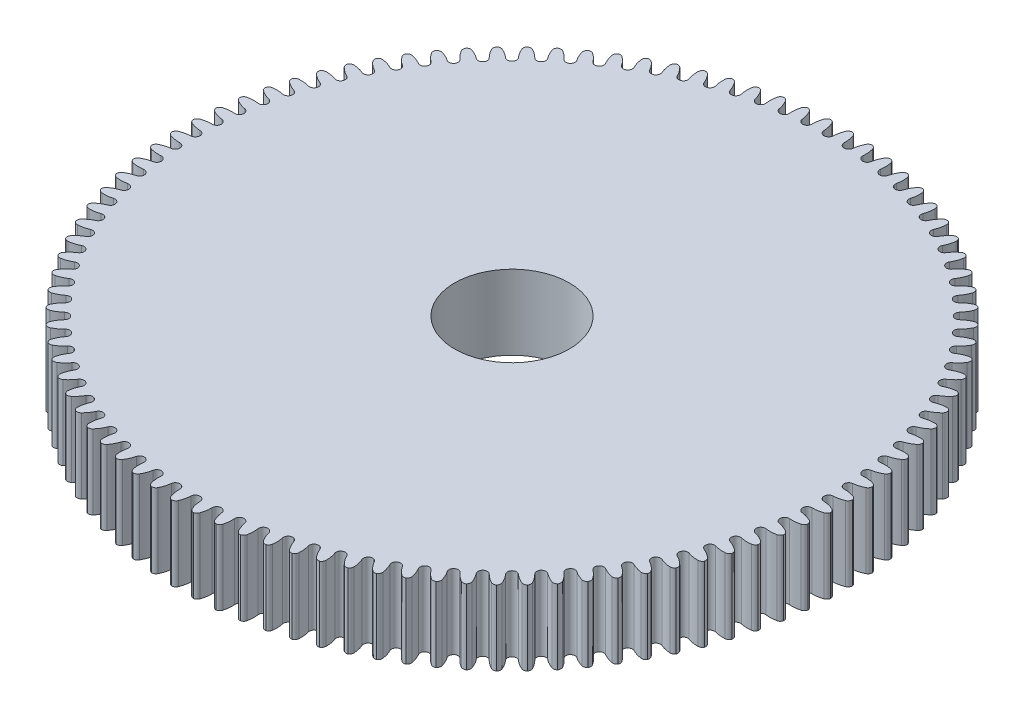
from build123d import *

# Parameters (mm, degrees)
SKETCH1_R           = 57.5
BOSS_EXTRUDE1_DEPTH = 13
CUT_EXTRUDE1_DEPTH  = 13
CIRPATTERN1_COUNT   = 96
SKETCH4_R           = 10
CUT_EXTRUDE3_DEPTH  = 13


with BuildPart() as part:
    # Sketch1 → Boss-Extrude1 (new body)
    with BuildSketch(Plane(origin=(0, 0, 0), x_dir=(1, 0, 0), z_dir=(0, 1, 0))):
        Circle(SKETCH1_R)
    extrude(amount=BOSS_EXTRUDE1_DEPTH)

    # Sketch3 → Cut-Extrude1 (cut)
    with BuildSketch(Plane.XZ):
        with BuildLine():
            ThreePointArc((1.210058579, -56.980264877), (0.924049006, -56.098471263), (0.799158179, -55.179905133))
            ThreePointArc((0.799158179, -55.179905133), (0, -54.416595794), (-0.799158179, -55.179905133))
            ThreePointArc((-0.799158179, -55.179905133), (-0.924049006, -56.098471263), (-1.210058579, -56.980264877))
            ThreePointArc((-1.210058579, -56.980264877), (-1.516463273, -57.341501027), (-1.973458227, -57.466124479))
            ThreePointArc((-1.973458227, -57.466124479), (3e-09, -57.5), (1.973458233, -57.466124479))
            ThreePointArc((1.973458233, -57.466124479), (1.516463276, -57.341501029), (1.210058579, -56.980264877))
        make_face()
    cut_extrude1 = extrude(amount=-CUT_EXTRUDE1_DEPTH, mode=Mode.SUBTRACT)

    # CirPattern1: Cut-Extrude1 ×96 about axis
    cirpattern1_axis = Axis((0, 0, 0), (0, 1, 0))
    for i in range(1, CIRPATTERN1_COUNT):
        add(cut_extrude1.rotate(cirpattern1_axis, i * 360 / CIRPATTERN1_COUNT), mode=Mode.SUBTRACT)

    # Sketch4 → Cut-Extrude3 (cut)
    with BuildSketch(Plane.XZ):
        Circle(SKETCH4_R)
    extrude(amount=-CUT_EXTRUDE3_DEPTH, mode=Mode.SUBTRACT)


solid = part.part
